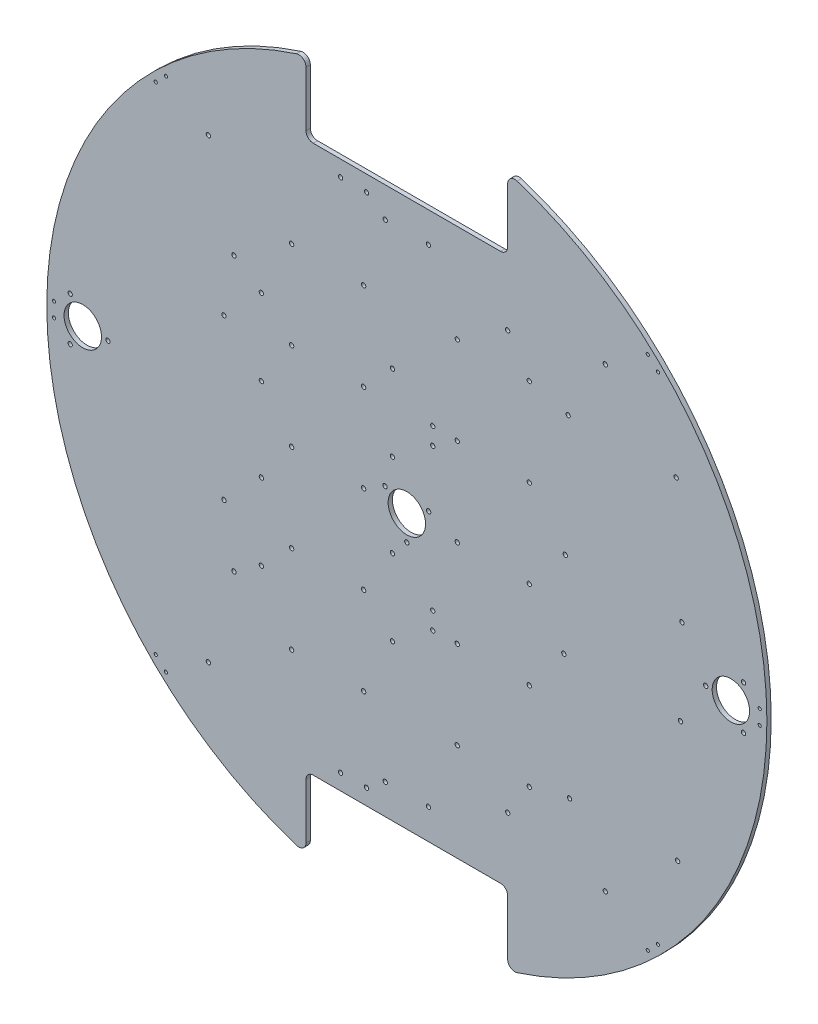
from build123d import *

# Parameters (mm, degrees)
SKETCH_1_R           = 250
EXTRUDE_1_DEPTH      = 3
CUT_EXTRUDE_1_DEPTH  = 4
CUT_EXTRUDE_2_DEPTH  = 4
FILLET_1_R           = 5
FILLET_2_R           = 5
FILLET_3_R           = 5
FILLET_4_R           = 5
FILLET_5_R           = 5
FILLET_6_R           = 5
FILLET_7_R           = 5
FILLET_8_R           = 5
SKETCH_4_R           = 1.5
CUT_EXTRUDE_3_DEPTH  = 4
SKETCH_15_R          = 1.5
CUT_EXTRUDE_5_DEPTH  = 4
SKETCH_17_R          = 1.5
CUT_EXTRUDE_7_DEPTH  = 4
SKETCH_18_R          = 13
SKETCH_18_R_2        = 1.5
CUT_EXTRUDE_8_DEPTH  = 4
SKETCH_19_R          = 1.5
CUT_EXTRUDE_9_DEPTH  = 4
SKETCH_21_R          = 1.5
CUT_EXTRUDE_11_DEPTH = 4
SKETCH_22_R          = 1.5
CUT_EXTRUDE_12_DEPTH = 4
SKETCH_23_R          = 1.1
CUT_EXTRUDE_13_DEPTH = 4


with BuildPart() as part:
    # ｽｹｯﾁ1 → ﾎﾞｽ - 押し出し1 (new body)
    with BuildSketch(Plane.XY):
        Circle(SKETCH_1_R)
    extrude(amount=-EXTRUDE_1_DEPTH)

    # ｽｹｯﾁ2 → ｶｯﾄ - 押し出し1 (cut, through all)
    with BuildSketch(Plane.XY):
        Polygon((0, 190), (70, 190), (70, 250), (0, 250), (-70, 250), (-70, 190), align=None)
    extrude(amount=-CUT_EXTRUDE_1_DEPTH, mode=Mode.SUBTRACT)

    # ｽｹｯﾁ3 → ｶｯﾄ - 押し出し2 (cut, through all)
    with BuildSketch(Plane.XY):
        Polygon((0, -250), (70, -250), (70, -190), (0, -190), (-70, -190), (-70, -250), align=None)
    extrude(amount=-CUT_EXTRUDE_2_DEPTH, mode=Mode.SUBTRACT)

    # ﾌｨﾚｯﾄ1
    fillet_1_edges = [part.edges().sort_by_distance(p)[0] for p in [
        (-70, 240, -1.5),
    ]]
    fillet(fillet_1_edges, radius=FILLET_1_R)

    # ﾌｨﾚｯﾄ2
    fillet_2_edges = [part.edges().sort_by_distance(p)[0] for p in [
        (70, 240, -1.5),
    ]]
    fillet(fillet_2_edges, radius=FILLET_2_R)

    # ﾌｨﾚｯﾄ3
    fillet_3_edges = [part.edges().sort_by_distance(p)[0] for p in [
        (70, 190, -1.5),
    ]]
    fillet(fillet_3_edges, radius=FILLET_3_R)

    # ﾌｨﾚｯﾄ4
    fillet_4_edges = [part.edges().sort_by_distance(p)[0] for p in [
        (-70, 190, -1.5),
    ]]
    fillet(fillet_4_edges, radius=FILLET_4_R)

    # ﾌｨﾚｯﾄ5
    fillet_5_edges = [part.edges().sort_by_distance(p)[0] for p in [
        (-70, -240, -1.5),
    ]]
    fillet(fillet_5_edges, radius=FILLET_5_R)

    # ﾌｨﾚｯﾄ6
    fillet_6_edges = [part.edges().sort_by_distance(p)[0] for p in [
        (70, -190, -1.5),
    ]]
    fillet(fillet_6_edges, radius=FILLET_6_R)

    # ﾌｨﾚｯﾄ7
    fillet_7_edges = [part.edges().sort_by_distance(p)[0] for p in [
        (70, -240, -1.5),
    ]]
    fillet(fillet_7_edges, radius=FILLET_7_R)

    # ﾌｨﾚｯﾄ8
    fillet_8_edges = [part.edges().sort_by_distance(p)[0] for p in [
        (-70, -190, -1.5),
    ]]
    fillet(fillet_8_edges, radius=FILLET_8_R)

    # ｽｹｯﾁ4 → ｶｯﾄ - 押し出し3 (cut, through all)
    with BuildSketch(Plane.XY):
        with Locations((15, 169)):
            Circle(SKETCH_4_R)
        with Locations((-15, 169)):
            Circle(SKETCH_4_R)
        with Locations((15, -169)):
            Circle(SKETCH_4_R)
        with Locations((-15, -169)):
            Circle(SKETCH_4_R)
        with Locations((-46, 179)):
            Circle(SKETCH_4_R)
        with Locations((-28, 179)):
            Circle(SKETCH_4_R)
        with Locations((-46, -179)):
            Circle(SKETCH_4_R)
        with Locations((-28, -179)):
            Circle(SKETCH_4_R)
    extrude(amount=-CUT_EXTRUDE_3_DEPTH, mode=Mode.SUBTRACT)

    # ｽｹｯﾁ15 → ｶｯﾄ - 押し出し5 (cut, through all)
    with BuildSketch(Plane.XY):
        with Locations((137.80005554, 158.464963614)):
            Circle(SKETCH_15_R)
        with Locations((137.80005554, -158.464963614)):
            Circle(SKETCH_15_R)
        with Locations((-137.80005554, -158.464963614)):
            Circle(SKETCH_15_R)
        with Locations((-137.80005554, 158.464963614)):
            Circle(SKETCH_15_R)
    extrude(amount=-CUT_EXTRUDE_5_DEPTH, mode=Mode.SUBTRACT)

    # ｽｹｯﾁ17 → ｶｯﾄ - 押し出し7 (cut, through all)
    with BuildSketch(Plane.XY):
        with Locations((-30, 122)):
            Circle(SKETCH_17_R)
        with Locations((35, 122)):
            Circle(SKETCH_17_R)
        with Locations((35, -122)):
            Circle(SKETCH_17_R)
        with Locations((-30, -122)):
            Circle(SKETCH_17_R)
        with Locations((35, 61)):
            Circle(SKETCH_17_R)
        with Locations((35, -61)):
            Circle(SKETCH_17_R)
        with Locations((-80, 122)):
            Circle(SKETCH_17_R)
        with Locations((-80, -122)):
            Circle(SKETCH_17_R)
        with Locations((85, -122)):
            Circle(SKETCH_17_R)
        with Locations((85, 122)):
            Circle(SKETCH_17_R)
        with Locations((-30, -61)):
            Circle(SKETCH_17_R)
        with Locations((-30, 61)):
            Circle(SKETCH_17_R)
        with Locations((-80, 61)):
            Circle(SKETCH_17_R)
        with Locations((-80, -61)):
            Circle(SKETCH_17_R)
        with Locations((85, -61)):
            Circle(SKETCH_17_R)
        with Locations((85, 61)):
            Circle(SKETCH_17_R)
        with Locations((-80, 0)):
            Circle(SKETCH_17_R)
        with Locations((-30, 0)):
            Circle(SKETCH_17_R)
        with Locations((35, 0)):
            Circle(SKETCH_17_R)
        with Locations((85, 0)):
            Circle(SKETCH_17_R)
    extrude(amount=-CUT_EXTRUDE_7_DEPTH, mode=Mode.SUBTRACT)

    # ｽｹｯﾁ18 → ｶｯﾄ - 押し出し8 (cut, through all)
    with BuildSketch(Plane.XY):
        Circle(SKETCH_18_R)
        with Locations((225, 0)):
            Circle(SKETCH_18_R)
        with Locations((-225, 0)):
            Circle(SKETCH_18_R)
        with Locations((-15.155444566, 8.75)):
            Circle(SKETCH_18_R_2)
        with Locations((15.155444566, 8.75)):
            Circle(SKETCH_18_R_2)
        with Locations((0, -17.5)):
            Circle(SKETCH_18_R_2)
        with Locations((-233.75, 15.155444566)):
            Circle(SKETCH_18_R_2)
        with Locations((-233.75, -15.155444566)):
            Circle(SKETCH_18_R_2)
        with Locations((-207.5, 0)):
            Circle(SKETCH_18_R_2)
        with Locations((233.75, 15.155444566)):
            Circle(SKETCH_18_R_2)
        with Locations((233.75, -15.155444566)):
            Circle(SKETCH_18_R_2)
        with Locations((207.5, 0)):
            Circle(SKETCH_18_R_2)
    extrude(amount=-CUT_EXTRUDE_8_DEPTH, mode=Mode.SUBTRACT)

    # ｽｹｯﾁ19 → ｶｯﾄ - 押し出し9 (cut, through all)
    with BuildSketch(Plane.XY):
        with Locations((187, 115)):
            Circle(SKETCH_19_R)
        with Locations((112, 115)):
            Circle(SKETCH_19_R)
        with Locations((110, 30)):
            Circle(SKETCH_19_R)
        with Locations((191, 30)):
            Circle(SKETCH_19_R)
        with Locations((190, -30)):
            Circle(SKETCH_19_R)
        with Locations((109, -30)):
            Circle(SKETCH_19_R)
        with Locations((113, -115)):
            Circle(SKETCH_19_R)
        with Locations((188, -115)):
            Circle(SKETCH_19_R)
    extrude(amount=-CUT_EXTRUDE_9_DEPTH, mode=Mode.SUBTRACT)

    # ｽｹｯﾁ21 → ｶｯﾄ - 押し出し11 (cut, through all)
    with BuildSketch(Plane.XY):
        with Locations((-120, 95)):
            Circle(SKETCH_21_R)
        with Locations((-120, -95)):
            Circle(SKETCH_21_R)
        with Locations((70, 145)):
            Circle(SKETCH_21_R)
        with Locations((70, -145)):
            Circle(SKETCH_21_R)
    extrude(amount=-CUT_EXTRUDE_11_DEPTH, mode=Mode.SUBTRACT)

    # ｽｹｯﾁ22 → ｶｯﾄ - 押し出し12 (cut, through all)
    with BuildSketch(Plane.XY):
        with Locations((18, 61.5)):
            Circle(SKETCH_22_R)
        with Locations((18, 49.5)):
            Circle(SKETCH_22_R)
        with Locations((-10, 82)):
            Circle(SKETCH_22_R)
        with Locations((-10, 29)):
            Circle(SKETCH_22_R)
        with Locations((-101, 29)):
            Circle(SKETCH_22_R)
        with Locations((-101, 82)):
            Circle(SKETCH_22_R)
        with Locations((-127, 55.5)):
            Circle(SKETCH_22_R)
        with Locations((18, -49.5)):
            Circle(SKETCH_22_R)
        with Locations((18, -61.5)):
            Circle(SKETCH_22_R)
        with Locations((-10, -82)):
            Circle(SKETCH_22_R)
        with Locations((-101, -82)):
            Circle(SKETCH_22_R)
        with Locations((-101, -29)):
            Circle(SKETCH_22_R)
        with Locations((-10, -29)):
            Circle(SKETCH_22_R)
        with Locations((-127, -55.5)):
            Circle(SKETCH_22_R)
    extrude(amount=-CUT_EXTRUDE_12_DEPTH, mode=Mode.SUBTRACT)

    # ｽｹｯﾁ23 → ｶｯﾄ - 押し出し13 (cut, through all)
    with BuildSketch(Plane.XY):
        with Locations((167.269231813, 179.178628002)):
            Circle(SKETCH_23_R)
        with Locations((174.340299625, 172.10756019)):
            Circle(SKETCH_23_R)
        with Locations((245, -5)):
            Circle(SKETCH_23_R)
        with Locations((245, 5)):
            Circle(SKETCH_23_R)
        with Locations((174.340299625, -172.10756019)):
            Circle(SKETCH_23_R)
        with Locations((167.269231813, -179.178628002)):
            Circle(SKETCH_23_R)
        with Locations((-167.269231813, -179.178628002)):
            Circle(SKETCH_23_R)
        with Locations((-174.340299625, -172.10756019)):
            Circle(SKETCH_23_R)
        with Locations((-245, -5)):
            Circle(SKETCH_23_R)
        with Locations((-245, 5)):
            Circle(SKETCH_23_R)
        with Locations((-174.340988951, 172.106870863)):
            Circle(SKETCH_23_R)
        with Locations((-167.269231813, 179.178628002)):
            Circle(SKETCH_23_R)
    extrude(amount=-CUT_EXTRUDE_13_DEPTH, mode=Mode.SUBTRACT)


solid = part.part
